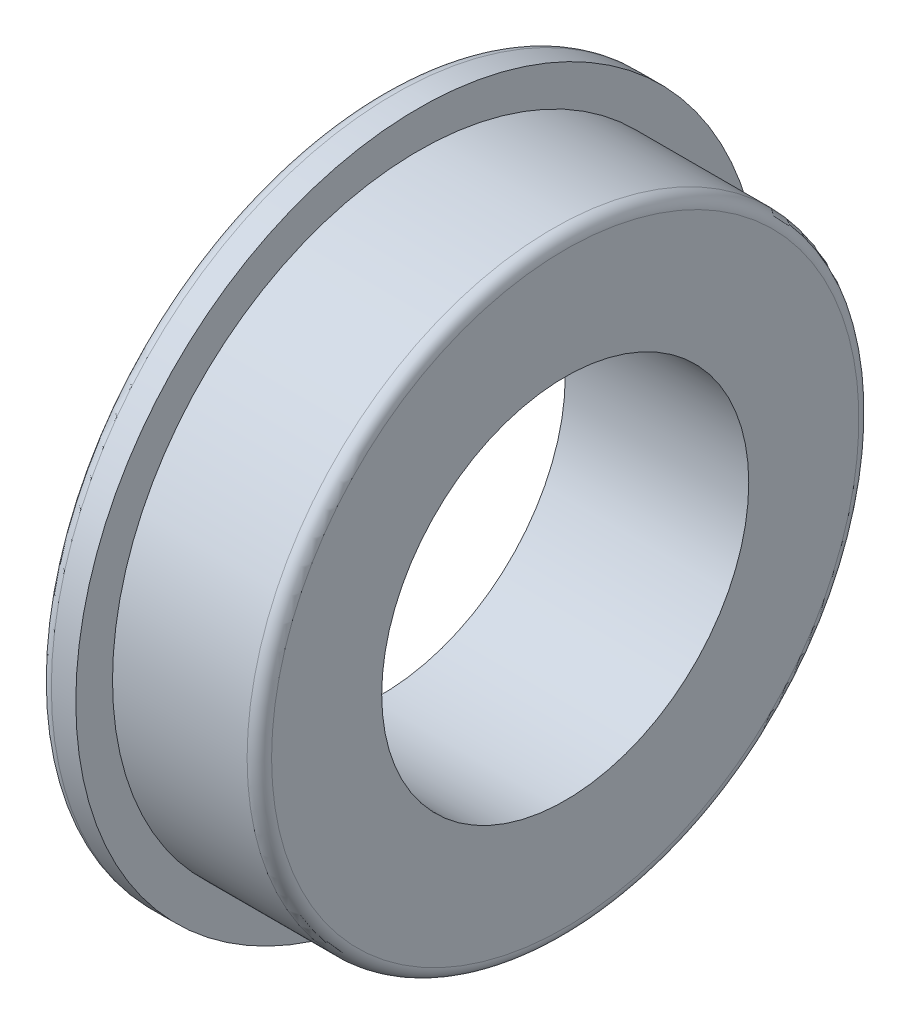
from build123d import *

# Parameters (mm, degrees)
FILLET1_R = 0.2


with BuildPart() as part:
    # Sketch1 → Revolve1 (revolve)
    with BuildSketch(Plane.XY):
        Polygon((0, 3), (0, 5.6), (0.6, 5.6), (0.6, 5), (3, 5), (3, 3), align=None)
    revolve(axis=Axis((0, 0, 0), (1, 0, 0)))

    # Fillet1
    fillet1_edges = [part.edges().sort_by_distance(p)[0] for p in [
        (3, -5, 0),
        (0, -5.6, 0),
    ]]
    fillet(fillet1_edges, radius=FILLET1_R)


solid = part.part
